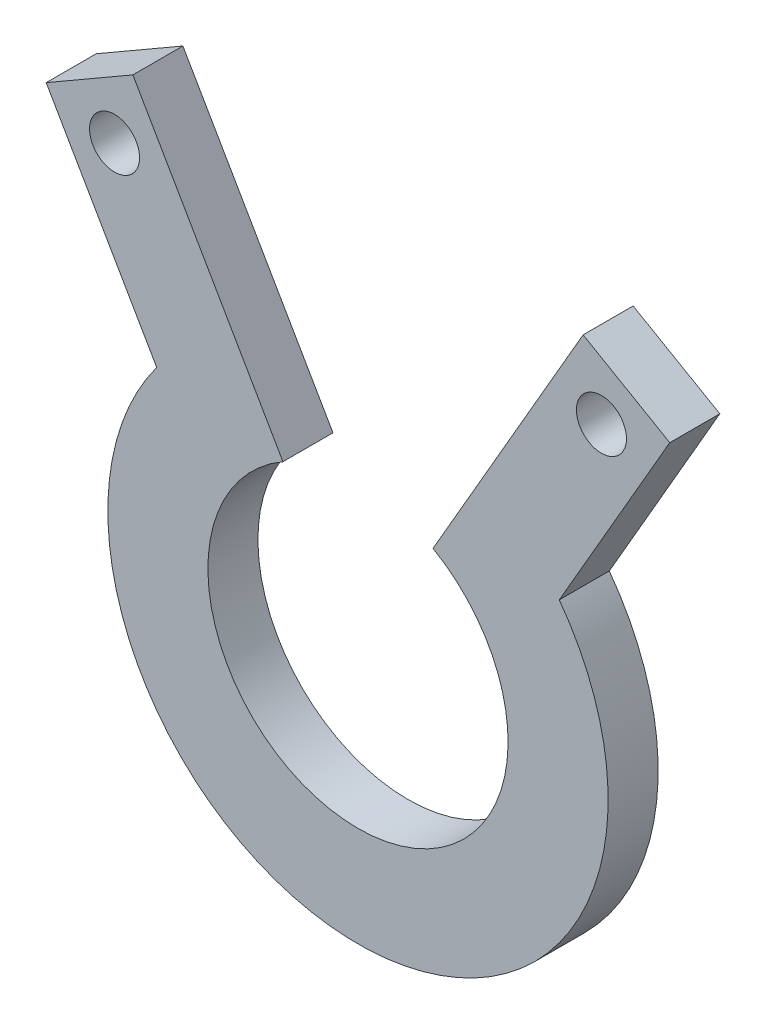
from build123d import *

# Parameters (mm, degrees)
SKETCH2_R           = 15.875
SKETCH2_R_2         = 12.7
SKETCH2_R_3         = 9.525
BOSS_EXTRUDE1_DEPTH = 3.175
SKETCH3_R           = 1.5875
BOSS_EXTRUDE2_DEPTH = 3.175
CUT_EXTRUDE1_DEPTH  = 3.175


with BuildPart() as part:
    # Sketch2 → Boss-Extrude1 (new body)
    with BuildSketch(Plane.XY):
        Circle(SKETCH2_R)
        Circle(SKETCH2_R_2, mode=Mode.SUBTRACT)
        Circle(SKETCH2_R_2)
        Circle(SKETCH2_R_3, mode=Mode.SUBTRACT)
    extrude(amount=BOSS_EXTRUDE1_DEPTH)

    # Sketch3 → Boss-Extrude2 (add)
    with BuildSketch(Plane.XY.offset(3.175)):
        with BuildLine():
            ThreePointArc((-12.77410023, 9.425390619), (-10.578949158, 11.836446245), (-7.9375, 13.748153285))
            Line((-7.9375, 13.748153285), (-14.2875, 24.746675913))
            Line((-14.2875, 24.746675913), (-19.786761314, 21.571675913))
            Line((-19.786761314, 21.571675913), (-13.436761314, 10.573153285))
            Line((-13.436761314, 10.573153285), (-12.77410023, 9.425390619))
        make_face()
        with Locations((-15.449630657, 20.409545256)):
            Circle(SKETCH3_R, mode=Mode.SUBTRACT)
        with BuildLine():
            Line((14.2875, 24.746675913), (7.9375, 13.748153285))
            ThreePointArc((7.9375, 13.748153285), (10.578949158, 11.836446245), (12.77410023, 9.425390619))
            Line((12.77410023, 9.425390619), (13.436761314, 10.573153285))
            Line((13.436761314, 10.573153285), (19.786761314, 21.571675913))
            Line((19.786761314, 21.571675913), (14.2875, 24.746675913))
        make_face()
        with Locations((15.449630657, 20.409545256)):
            Circle(SKETCH3_R, mode=Mode.SUBTRACT)
    extrude(amount=-BOSS_EXTRUDE2_DEPTH)

    # Sketch5 → Cut-Extrude1 (cut)
    with BuildSketch(Plane.XY.offset(3.175)):
        with BuildLine():
            Line((-7.9375, 13.748153285), (0, 0))
            Line((0, 0), (7.9375, 13.748153285))
            ThreePointArc((7.9375, 13.748153285), (0, 15.875), (-7.9375, 13.748153285))
        make_face()
    extrude(amount=-CUT_EXTRUDE1_DEPTH, mode=Mode.SUBTRACT)


solid = part.part
